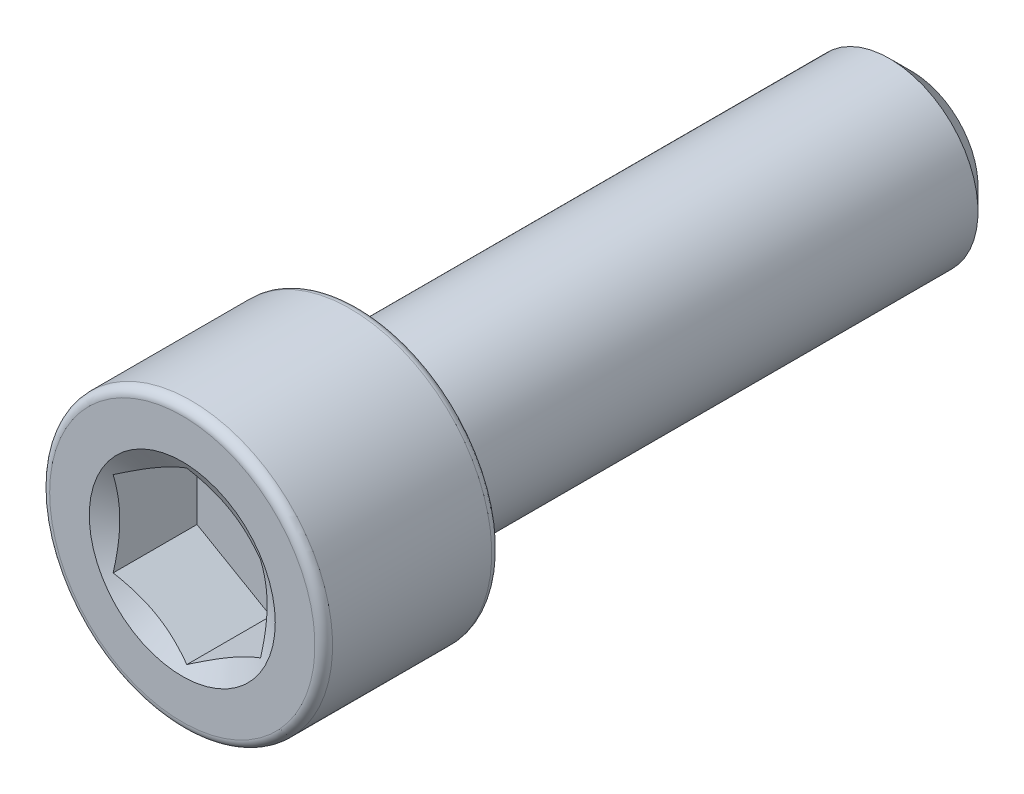
from build123d import *

# Parameters (mm, degrees)
CUT_EXTRUDE1_START = 3.14325
CUT_EXTRUDE1_DEPTH = 0.762


with BuildPart() as part:
    # Sketch2 → Revolve1 (revolve)
    with BuildSketch(Plane(origin=(0, 0, 0), x_dir=(0, 0, -1), z_dir=(1, 0, 0)), mode=Mode.PRIVATE) as revolve1_sk:
        with BuildLine():
            Line((3.14325, 0), (3.14325, 0.5715))
            Line((3.14325, 0.5715), (2.95275, 0.762))
            Line((2.95275, 0.762), (-1.61925, 0.762))
            Line((-1.61925, 0.762), (-1.61925, 1.143))
            ThreePointArc((-1.61925, 1.143), (-1.641568463, 1.196881537), (-1.69545, 1.2192))
            Line((-1.69545, 1.2192), (-3.06705, 1.2192))
            ThreePointArc((-3.06705, 1.2192), (-3.120931537, 1.196881537), (-3.14325, 1.143))
            Line((-3.14325, 1.143), (-3.14325, 0))
            Line((-3.14325, 0), (3.14325, 0))
        make_face()
    revolve(revolve1_sk.sketch.rotate(Axis((0, 0, -3.14325), (0, 0, 1)), 90), axis=Axis((0, 0, -3.14325), (0, 0, 1)))

    # Sketch3 → Cut-Extrude1 (cut)
    with BuildSketch(Plane.XY.offset(CUT_EXTRUDE1_START)):
        Polygon((-0.635, 0.366617421), (-0.635, -0.366617421), (0, -0.733234842), (0.635, -0.366617421), (0.635, 0.366617421), (0, 0.733234842), align=None)
    extrude(amount=-CUT_EXTRUDE1_DEPTH, mode=Mode.SUBTRACT)

    # Cut-Extrude2 cone 1 section (through the dimple's axis) → Cut-Extrude2 (revolve, cut)
    with BuildSketch(Plane(origin=(0, 0, 3.14325), x_dir=(0, -1, 0), z_dir=(1, 0, 0))):
        Polygon((0, 0), (0.801529035, 0), (0, 0.462763004), align=None)
    revolve(axis=Axis((0, 0, 3.14325), (0, 0, -1)), mode=Mode.SUBTRACT)


solid = part.part
